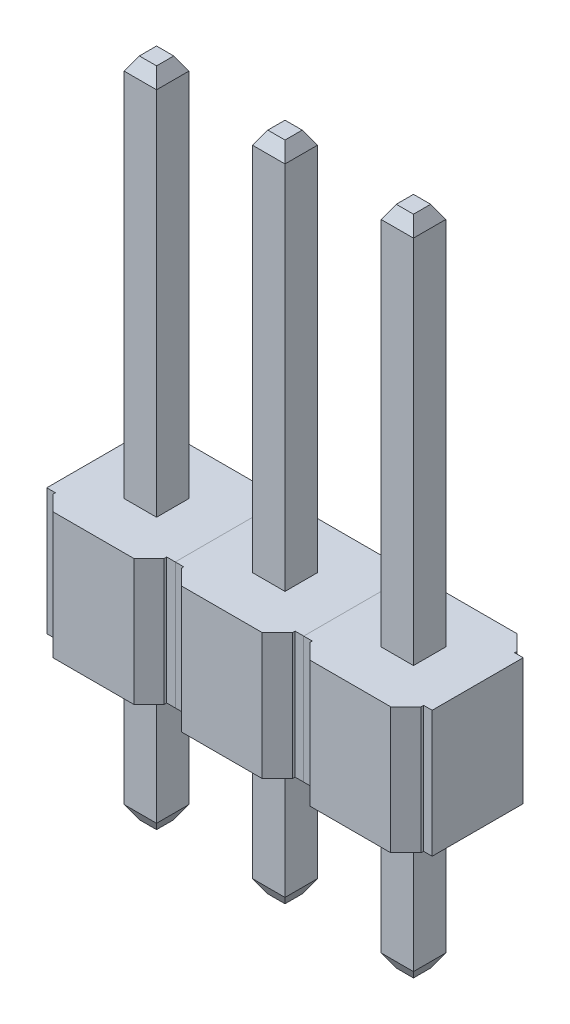
from build123d import *

# Parameters (mm, degrees)
HEADER_PROFILE_W             = 0.64
HEADER_PROFILE_H             = 0.64
END_PIN_PROFILE_SIZE         = 0.15
END_PIN_PROFILE_SIZE2        = 0.259807621
END_PIN_PROFILE_PART_2_SIZE  = 0.15
END_PIN_PROFILE_PART_2_SIZE2 = 0.259807621
BASE_BODY_DEPTH              = 2.5
BB_CHAMFER_SIZE              = 0.3
LP_ALL_COUNT                 = 2
LP_ALL_PITCH                 = 2.54
LP_ALL_2_COUNT               = 2
LP_ALL_2_PITCH               = 2.54


with BuildPart() as part:
    # PIN PROFILE: sweep along a path in HEADER PATH
    with BuildLine(Plane(origin=(0, 0, 0), x_dir=(0, 0, -1), z_dir=(1, 0, 0))) as pin_profile_path:
        Line((0, -3), (0, 0))
        Line((0, 0), (0, 10.08))
    # HEADER PROFILE → PIN PROFILE (sweep)
    with BuildSketch(Plane(origin=(0, 0, 0), x_dir=(1, 0, 0), z_dir=(0, 1, 0))):
        Rectangle(HEADER_PROFILE_W, HEADER_PROFILE_H)
    sweep(path=pin_profile_path.line)

    # END PIN PROFILE
    end_pin_profile_edges = [part.edges().sort_by_distance(p)[0] for p in [
        (0, 10.08, -0.32),
        (-0.32, 10.08, 0),
        (0, 10.08, 0.32),
        (0.32, 10.08, 0),
    ]]
    end_pin_profile_side = [part.faces().sort_by_distance(p)[0] for p in [
        (0, 10.08, 0),
    ]]
    chamfer(end_pin_profile_edges, length=END_PIN_PROFILE_SIZE, length2=END_PIN_PROFILE_SIZE2, reference=end_pin_profile_side[0])

    # END PIN PROFILE part 2
    end_pin_profile_part_2_edges = [part.edges().sort_by_distance(p)[0] for p in [
        (0.32, -3, 0),
        (0, -3, -0.32),
        (-0.32, -3, 0),
        (0, -3, 0.32),
    ]]
    end_pin_profile_part_2_side = [part.faces().sort_by_distance(p)[0] for p in [
        (0, -3, 0),
    ]]
    chamfer(end_pin_profile_part_2_edges, length=END_PIN_PROFILE_PART_2_SIZE, length2=END_PIN_PROFILE_PART_2_SIZE2, reference=end_pin_profile_part_2_side[0])


with BuildPart() as body_2:
    # Эскиз4 → BASE BODY (new body)
    with BuildSketch(Plane(origin=(0, 0, 0), x_dir=(1, 0, 0), z_dir=(0, 1, 0))):
        Polygon((-1.1, 0.9), (-1.1, 1.25), (1.1, 1.25), (1.1, 0.9), (1.27, 0.9), (1.27, -0.9), (1.1, -0.9), (1.1, -1.25), (-1.1, -1.25), (-1.1, -0.9), (-1.27, -0.9), (-1.27, 0.9), align=None)
    extrude(amount=BASE_BODY_DEPTH)

    # BB CHAMFER
    bb_chamfer_edges = [body_2.edges().sort_by_distance(p)[0] for p in [
        (1.1, 1.25, 1.25),
        (-1.1, 1.25, 1.25),
        (-1.1, 1.25, -1.25),
        (1.1, 1.25, -1.25),
    ]]
    chamfer(bb_chamfer_edges, length=BB_CHAMFER_SIZE)


with BuildPart() as lp_all_1:
    # LP ALL: pattern copy
    add(body_2.part.moved(Location(Vector(-1, 0, 0) * (1 * LP_ALL_PITCH))))


with BuildPart() as lp_all_2:
    # LP ALL: pattern copy
    add(part.part.moved(Location(Vector(-1, 0, 0) * (1 * LP_ALL_PITCH))))


with BuildPart() as lp_all_2_1:
    # LP ALL 2: pattern copy
    add(body_2.part.moved(Location(Vector(1, 0, 0) * (1 * LP_ALL_2_PITCH))))


with BuildPart() as lp_all_2_2:
    # LP ALL 2: pattern copy
    add(part.part.moved(Location(Vector(1, 0, 0) * (1 * LP_ALL_2_PITCH))))


solid = Compound([part.part, body_2.part, lp_all_1.part, lp_all_2.part, lp_all_2_1.part, lp_all_2_2.part])
